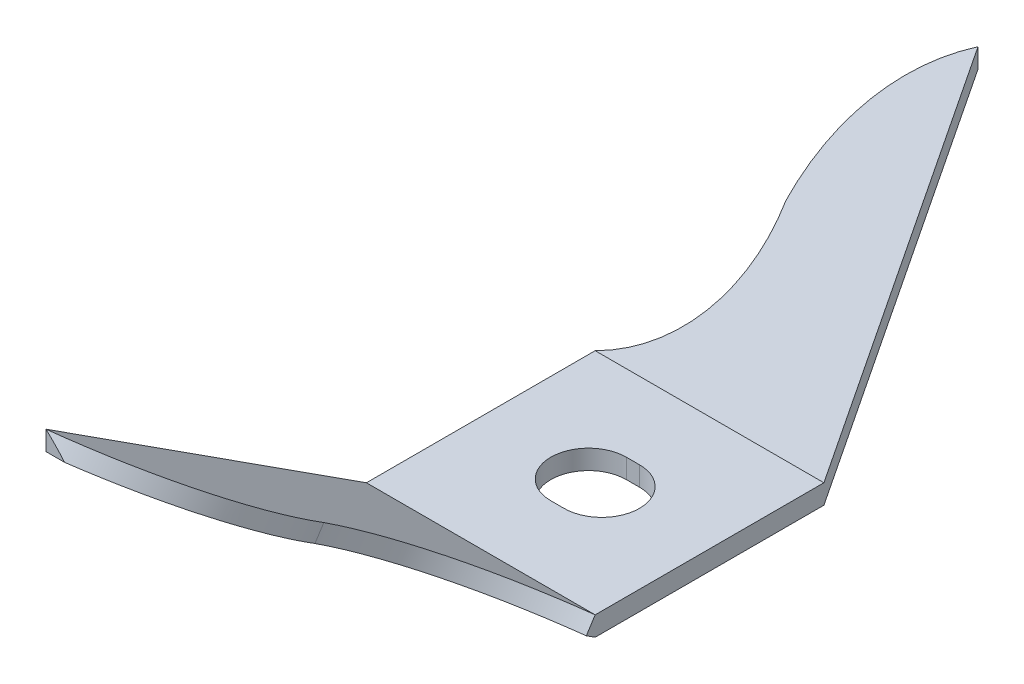
from build123d import *

# Parameters (mm, degrees)
SKETCH1_W           = 15.24
SKETCH1_H           = 15.24
BOSS_EXTRUDE1_DEPTH = 1.2954
BOSS_EXTRUDE2_DEPTH = 15.24
CUT_EXTRUDE1_DEPTH  = 15.24
CUT_EXTRUDE2_DEPTH  = 15.24


with BuildPart() as part:
    # Sketch1 → Boss-Extrude1 (new body)
    with BuildSketch(Plane(origin=(0, 0, 0), x_dir=(1, 0, 0), z_dir=(0, 1, 0))):
        Rectangle(SKETCH1_W, SKETCH1_H)
        with BuildLine():
            Line((-0.43942, 2.5146), (0.43942, 2.5146))
            ThreePointArc((0.43942, 2.5146), (2.95402, 0), (0.43942, -2.5146))
            Line((0.43942, -2.5146), (-0.43942, -2.5146))
            ThreePointArc((-0.43942, -2.5146), (-2.95402, 0), (-0.43942, 2.5146))
        make_face(mode=Mode.SUBTRACT)
    extrude(amount=BOSS_EXTRUDE1_DEPTH)

    # Sketch3 → Boss-Extrude2 (add)
    with BuildSketch(Plane.ZY.offset(7.62)):
        Polygon((7.62, 1.2954), (28.967378653, 15.059462796), (28.967378653, 13.764062796), (7.62, 0), align=None)
        Polygon((-7.62, 1.2954), (-17.885578899, 21.321091109), (-17.885578899, 20.025691109), (-7.62, 0), align=None)
    extrude(amount=-BOSS_EXTRUDE2_DEPTH)

    # Sketch4 → Cut-Extrude1 (cut)
    with BuildSketch(Plane(origin=(0, -2.555384203, 1.647624714), x_dir=(1, 0, 0), z_dir=(0, 0.840447978, -0.541892236))):
        with BuildLine():
            Line((7.62, -7.106180798), (7.62, -32.506180798))
            Line((7.62, -32.506180798), (-7.62, -32.506180798))
            ThreePointArc((-7.62, -32.506180798), (-1.894391171, -27.153773172), (0, -19.548370753))
            ThreePointArc((0, -19.548370753), (2.118358532, -12.291259766), (7.62, -7.106180798))
        make_face()
    extrude(amount=-CUT_EXTRUDE1_DEPTH, mode=Mode.SUBTRACT)

    # Sketch5 → Cut-Extrude2 (cut)
    with BuildSketch(Plane(origin=(0, -2.823741084, -5.508444021), x_dir=(1, 0, 0), z_dir=(0, 0.456175683, 0.889889738))):
        with BuildLine():
            Line((-7.62, 4.628821871), (-7.62, 27.132386357))
            Line((-7.62, 27.132386357), (7.62, 27.132386357))
            ThreePointArc((7.62, 27.132386357), (2.681671235, 22.223683301), (0, 15.797868484))
            ThreePointArc((0, 15.797868484), (-2.22452861, 9.131668969), (-7.62, 4.628821871))
        make_face()
    extrude(amount=-CUT_EXTRUDE2_DEPTH, mode=Mode.SUBTRACT)


solid = part.part
